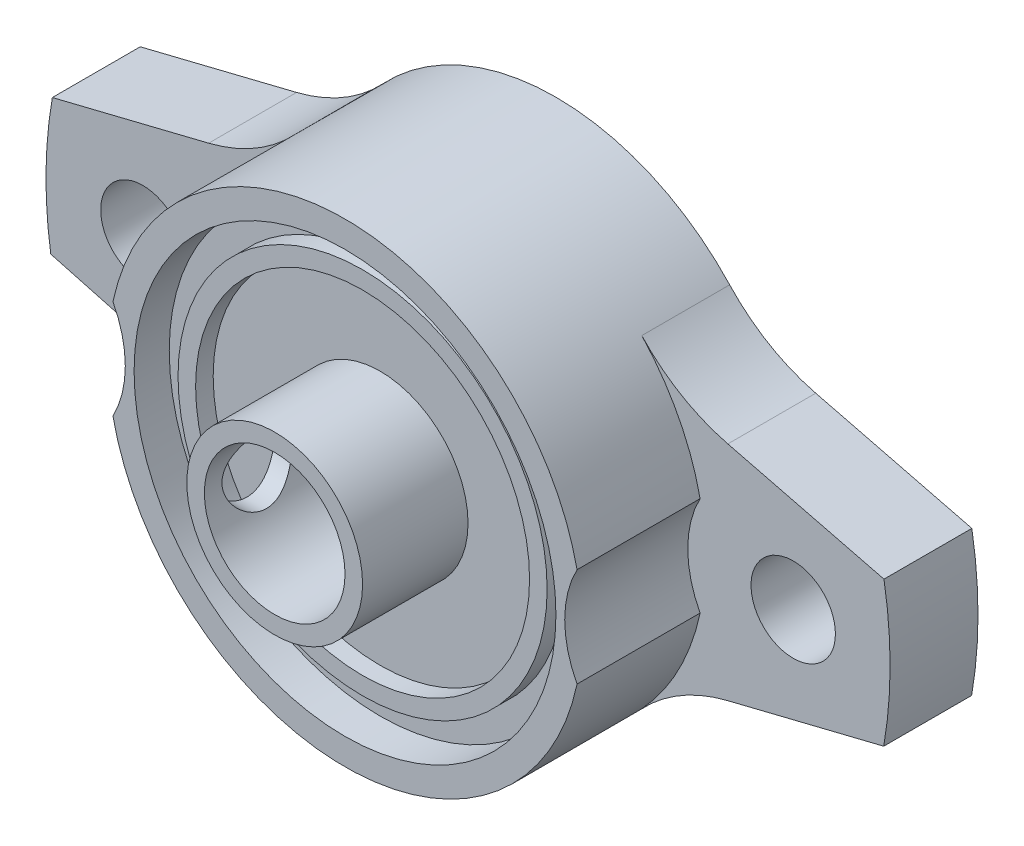
from build123d import *

# Parameters (mm, degrees)
SKETCH_1_R          = 2.4
EXTRUDE_1_DEPTH     = 5
SKETCH_2_R          = 13.5
EXTRUDE_2_DEPTH     = 5
SKETCH_3_R          = 13.5
SKETCH_3_R_2        = 12
EXTRUDE_3_DEPTH     = 2
SKETCH_4_R          = 5
SKETCH_4_R_2        = 4
EXTRUDE_4_DEPTH     = 6
SKETCH_5_R          = 6
CUT_EXTRUDE_1_DEPTH = 7
SKETCH_6_R          = 4
CUT_EXTRUDE_2_DEPTH = 13
SKETCH_7_R          = 10.5
SKETCH_7_R_2        = 9.5
EXTRUDE_5_DEPTH     = 1
SKETCH_8_R          = 2
CUT_EXTRUDE_3_DEPTH = 3


with BuildPart() as part:
    # 草图1 → 凸台-拉伸1 (new body)
    with BuildSketch(Plane.XY):
        with BuildLine():
            Line((-23.650515621, 4.155817481), (-14.755275826, 6.353883931))
            ThreePointArc((-14.755275826, 6.353883931), (-12.096586798, 7.435137426), (-9.854528975, 9.227039541))
            ThreePointArc((-9.854528975, 9.227039541), (0.022244584, 13.499981673), (9.884883075, 9.19451394))
            ThreePointArc((9.884883075, 9.19451394), (12.1232727, 7.393904675), (14.781202624, 6.30395497))
            Line((14.781202624, 6.30395497), (23.663193746, 4.083009896))
            ThreePointArc((23.663193746, 4.083009896), (24.012837039, -0.036951588), (23.650515621, -4.155817481))
            Line((23.650515621, -4.155817481), (14.755275826, -6.353883931))
            ThreePointArc((14.755275826, -6.353883931), (12.096586798, -7.435137426), (9.854528975, -9.227039541))
            ThreePointArc((9.854528975, -9.227039541), (-0.168191571, -13.498952241), (-10.081364571, -8.978646244))
            ThreePointArc((-10.081364571, -8.978646244), (-12.295346053, -7.120754011), (-14.948193848, -5.973637572))
            Line((-14.948193848, -5.973637572), (-23.740665236, -3.605346339))
            ThreePointArc((-23.740665236, -3.605346339), (-24.011245735, 0.278902058), (-23.650515621, 4.155817481))
        make_face()
        with Locations((18.5, 0)):
            Circle(SKETCH_1_R, mode=Mode.SUBTRACT)
        with Locations((-18.5, 0)):
            Circle(SKETCH_1_R, mode=Mode.SUBTRACT)
    extrude(amount=EXTRUDE_1_DEPTH)

    # 草图2 → 凸台-拉伸2 (add)
    with BuildSketch(Plane.XY.offset(5)):
        Circle(SKETCH_2_R)
    extrude(amount=EXTRUDE_2_DEPTH)

    # 草图3 → 凸台-拉伸3 (add)
    with BuildSketch(Plane.XY.offset(10)):
        Circle(SKETCH_3_R)
        Circle(SKETCH_3_R_2, mode=Mode.SUBTRACT)
    extrude(amount=EXTRUDE_3_DEPTH)

    # 草图4 → 凸台-拉伸4 (add)
    with BuildSketch(Plane.XY.offset(10)):
        Circle(SKETCH_4_R)
        Circle(SKETCH_4_R_2, mode=Mode.SUBTRACT)
    extrude(amount=EXTRUDE_4_DEPTH)

    # 草图5 → 切除-拉伸1 (cut)
    with BuildSketch(Plane.XY.offset(5)):
        with Locations((-18.5, 0)):
            Circle(SKETCH_5_R)
        with Locations((18.5, 0)):
            Circle(SKETCH_5_R)
    extrude(amount=CUT_EXTRUDE_1_DEPTH, mode=Mode.SUBTRACT)

    # 草图6 → 切除-拉伸2 (cut)
    with BuildSketch(Plane.XY.offset(10)):
        Circle(SKETCH_6_R)
    extrude(amount=-CUT_EXTRUDE_2_DEPTH, mode=Mode.SUBTRACT)

    # 草图7 → 凸台-拉伸5 (add)
    with BuildSketch(Plane.XY.offset(10)):
        Circle(SKETCH_7_R)
        Circle(SKETCH_7_R_2, mode=Mode.SUBTRACT)
    extrude(amount=EXTRUDE_5_DEPTH)

    # 草图8 → 切除-拉伸3 (cut)
    with BuildSketch(Plane.ZY.offset(5)):
        with Locations((13, 0)):
            Circle(SKETCH_8_R)
    extrude(amount=-CUT_EXTRUDE_3_DEPTH, mode=Mode.SUBTRACT)


solid = part.part
